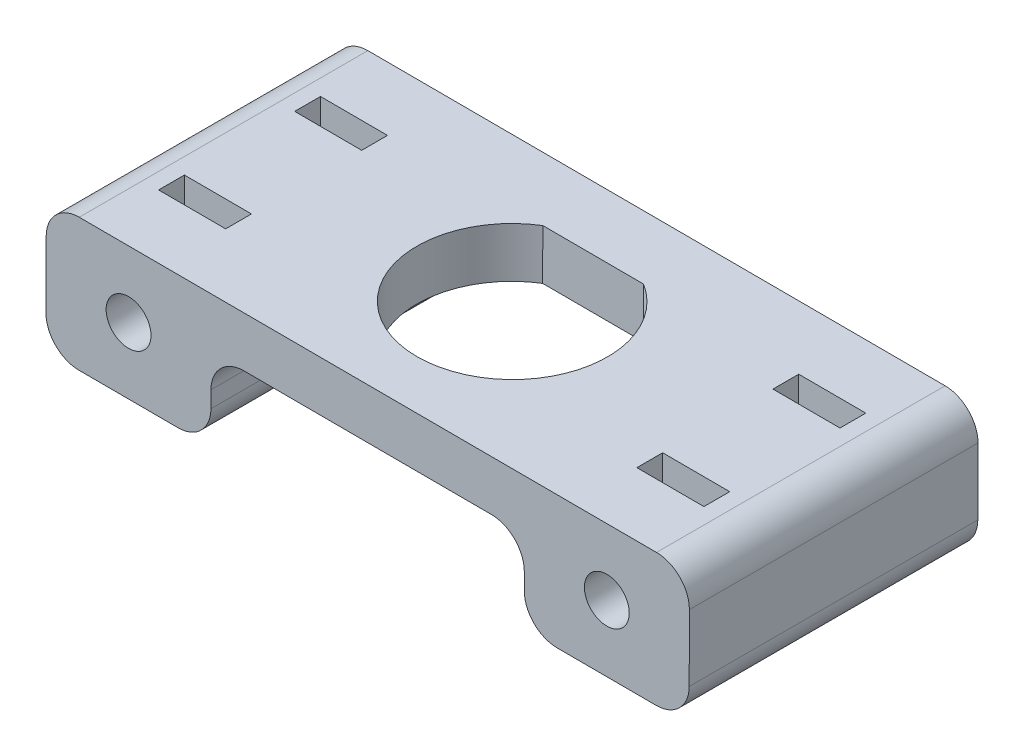
from build123d import *

# Parameters (mm, degrees)
BOSS_EXTRUDE1_DEPTH   = 22.225
CUT_EXTRUDE1_REACH    = 12.357
FILLET1_R             = 2.54
F_4_CLEARANCE_HOLE1_D = 3.4544
SKETCH6_W             = 5.1625
SKETCH6_H             = 1.9875
CUT_EXTRUDE2_DEPTH    = 8.255


with BuildPart() as part:
    # Sketch1 → Boss-Extrude1 (new body)
    with BuildSketch(Plane.XY):
        Polygon((-96.82388635, -119.84135975), (-47.294090685, -119.983632078), (-47.323432737, -130.198589936), (-60.023380343, -130.162109852), (-60.005140301, -123.812136049), (-84.135040753, -123.742823889), (-84.153280795, -130.092797692), (-96.853228402, -130.056317608), align=None)
    extrude(amount=BOSS_EXTRUDE1_DEPTH)

    # Sketch2 → Cut-Extrude1 (cut, up to next)
    with BuildSketch(Plane(origin=(-0.345035492, -120.118491334, 0), x_dir=(0.999995875, -0.002872448, 0), z_dir=(0.002872448, 0.999995875, 0)), mode=Mode.PRIVATE) as cut_extrude1_sk1:
        with BuildLine():
            Line((-67.837073069, -4.8775), (-75.591424695, -4.8775))
            ThreePointArc((-75.591424695, -4.8775), (-71.714248882, -18.4546875), (-67.837073069, -4.8775))
        make_face()
    cut_extrude1_tool1 = extrude(cut_extrude1_sk1.sketch, amount=-CUT_EXTRUDE1_REACH, mode=Mode.PRIVATE) & part.part
    add(cut_extrude1_tool1.solids().sort_by_distance((-72.058989, -119.912496, 11.350092))[0], mode=Mode.SUBTRACT)

    # Fillet1
    fillet1_edges = [part.edges().sort_by_distance(p)[0] for p in [
        (-96.82388635, -119.84135975, 11.1125),
        (-47.294090685, -119.983632078, 11.1125),
        (-47.323432737, -130.198589936, 11.1125),
        (-60.023380343, -130.162109852, 11.1125),
        (-60.005140301, -123.812136049, 11.1125),
        (-84.135040753, -123.742823889, 11.1125),
        (-84.153280795, -130.092797692, 11.1125),
        (-96.853228402, -130.056317608, 11.1125),
    ]]
    fillet(fillet1_edges, radius=FILLET1_R)

    # #4 Clearance Hole1 (through all)
    with Locations(Plane.XY.offset(22.225)):
        with Locations((-90.488583573, -124.967078721), (-53.658735514, -125.072870965)):
            Hole(F_4_CLEARANCE_HOLE1_D / 2)

    # Sketch6 → Cut-Extrude2 (cut)
    with BuildSketch(Plane(origin=(-0.345035492, -120.118491334, 0), x_dir=(0.999995875, -0.002872448, 0), z_dir=(0.002872448, 0.999995875, 0))):
        with Locations((-90.129248882, -16.35125)):
            Rectangle(SKETCH6_W, SKETCH6_H)
        with Locations((-90.129248882, -5.87375)):
            Rectangle(SKETCH6_W, SKETCH6_H)
        with Locations((-53.299248882, -5.87375)):
            Rectangle(SKETCH6_W, SKETCH6_H)
        with Locations((-53.299248882, -16.35125)):
            Rectangle(SKETCH6_W, SKETCH6_H)
    extrude(amount=-CUT_EXTRUDE2_DEPTH, mode=Mode.SUBTRACT)


solid = part.part
